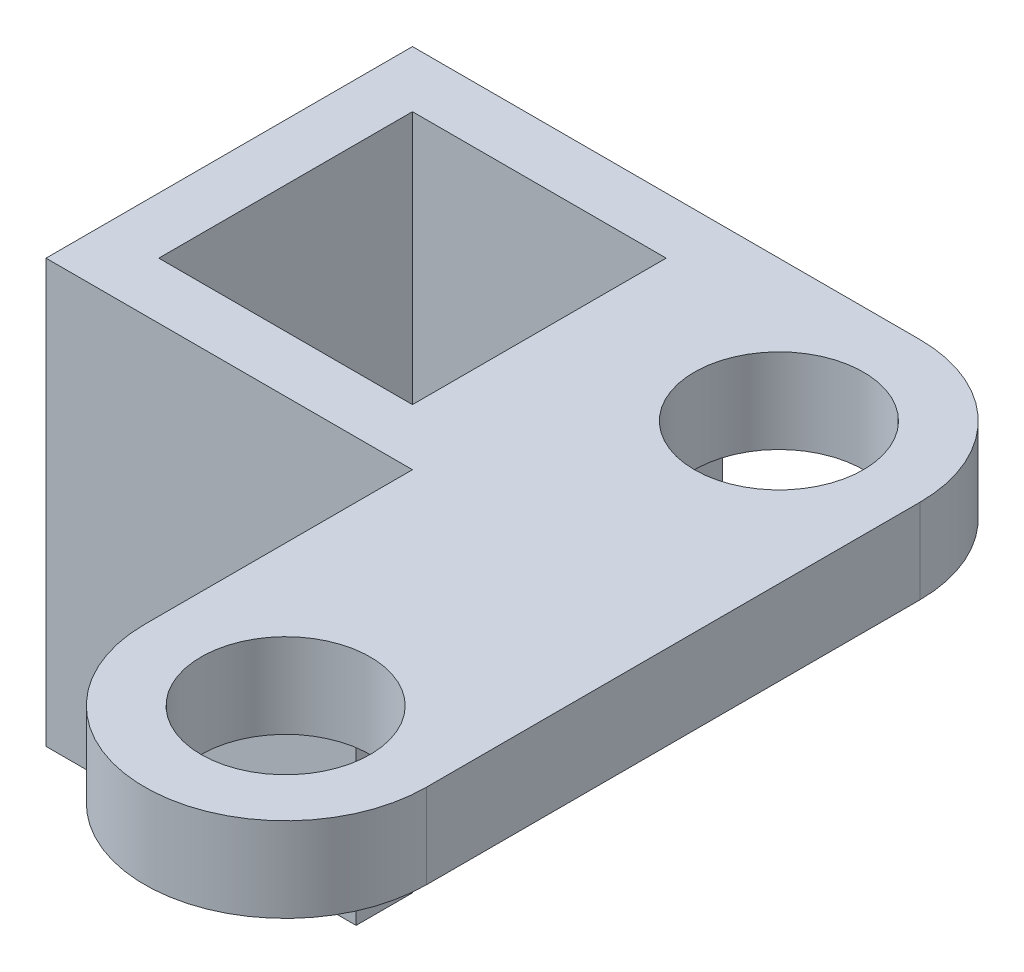
from build123d import *

# Parameters (mm, degrees)
SKETCH1_R           = 3
BOSS_EXTRUDE1_DEPTH = 3
SKETCH2_R           = 3
CUT_EXTRUDE1_DEPTH  = 3
SKETCH3_W           = 9
SKETCH3_H           = 9
BOSS_EXTRUDE2_DEPTH = 3
BOSS_EXTRUDE3_DEPTH = 12


with BuildPart() as part:
    # Sketch1 → Boss-Extrude1 (new body)
    with BuildSketch(Plane(origin=(0, 0, 0), x_dir=(1, 0, 0), z_dir=(0, 1, 0))):
        with BuildLine():
            Line((-3.269734365, -7.845727727), (-3.269734365, 9.654272273))
            ThreePointArc((-3.269734365, 9.654272273), (1.730265635, 14.654272273), (6.730265635, 9.654272273))
            Line((6.730265635, 9.654272273), (6.730265635, -7.845727727))
            ThreePointArc((6.730265635, -7.845727727), (1.730265635, -12.845727727), (-3.269734365, -7.845727727))
        make_face()
        with Locations((1.730265635, -7.845727727)):
            Circle(SKETCH1_R, mode=Mode.SUBTRACT)
    extrude(amount=BOSS_EXTRUDE1_DEPTH)

    # Sketch2 → Cut-Extrude1 (cut)
    with BuildSketch(Plane(origin=(0, 3, 0), x_dir=(1, 0, 0), z_dir=(0, 1, 0))):
        with Locations((1.730265635, 9.654272273)):
            Circle(SKETCH2_R)
    extrude(amount=-CUT_EXTRUDE1_DEPTH, mode=Mode.SUBTRACT)

    # Sketch3 → Boss-Extrude2 (add)
    with BuildSketch(Plane(origin=(0, 0, 0), x_dir=(-1, 0, 0), z_dir=(0, -1, 0))):
        with BuildLine():
            Line((-1.730265635, 14.654272273), (16.269734365, 14.654272273))
            Line((16.269734365, 14.654272273), (16.269734365, 1.654272273))
            Line((16.269734365, 1.654272273), (3.269734365, 1.654272273))
            Line((3.269734365, 1.654272273), (3.269734365, 9.654272273))
            ThreePointArc((3.269734365, 9.654272273), (1.805268271, 13.189806179), (-1.730265635, 14.654272273))
        make_face()
        with Locations((9.769734365, 8.154272273)):
            Rectangle(SKETCH3_W, SKETCH3_H, mode=Mode.SUBTRACT)
    extrude(amount=-BOSS_EXTRUDE2_DEPTH)

    # Sketch4 → Boss-Extrude3 (add)
    with BuildSketch(Plane(origin=(0, 0, 0), x_dir=(-1, 0, 0), z_dir=(0, -1, 0))):
        Polygon((5.269734365, 12.654272273), (5.269734365, 14.654272273), (16.269734365, 14.654272273), (16.269734365, 1.654272273), (5.269734365, 1.654272273), (5.269734365, 3.654272273), (14.269734365, 3.654272273), (14.269734365, 12.654272273), align=None)
    extrude(amount=BOSS_EXTRUDE3_DEPTH)


solid = part.part
